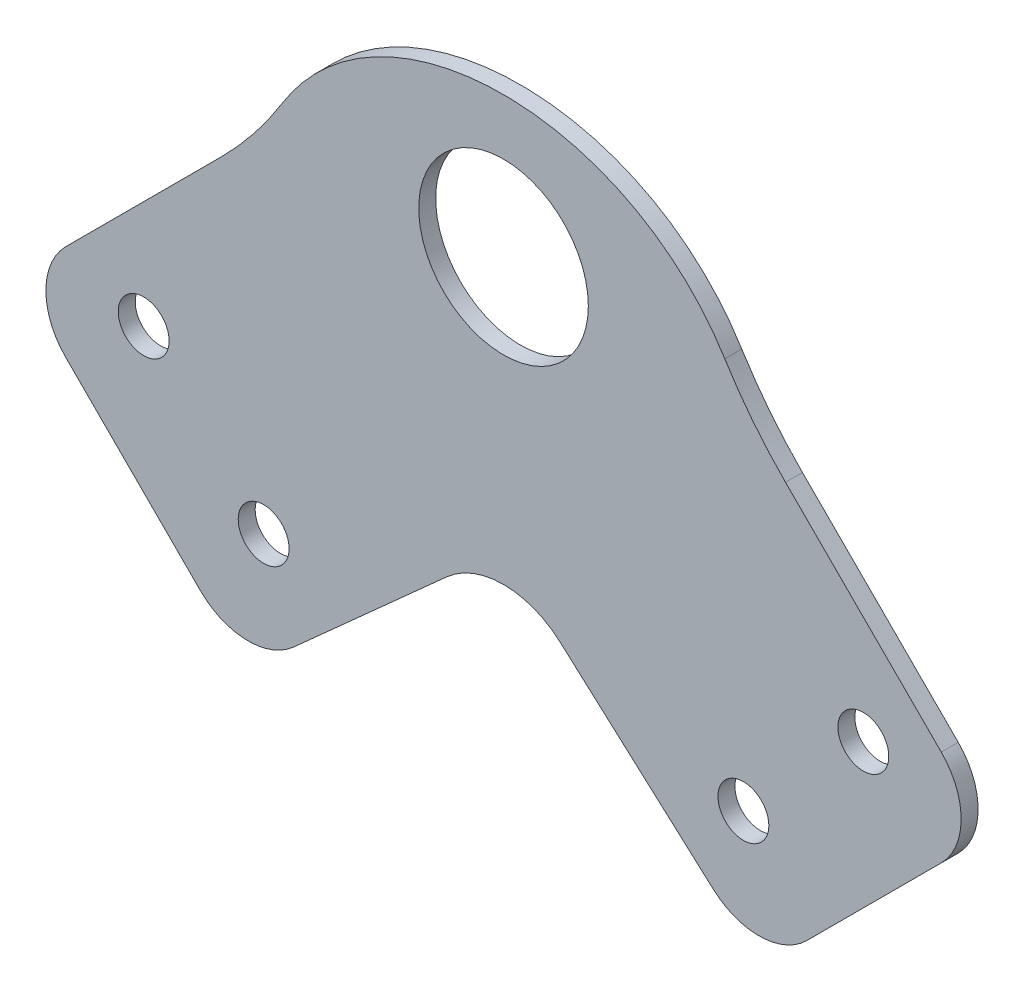
from build123d import *

# Parameters (mm, degrees)
SKETCH1_R           = 10
SKETCH1_R_2         = 3
BOSS_EXTRUDE1_DEPTH = 2
FILLET1_R           = 10
FILLET2_R           = 8
FILLET3_R           = 50


with BuildPart() as part:
    # Sketch1 → Boss-Extrude1 (new body)
    with BuildSketch(Plane.XY):
        with BuildLine():
            Line((-57.275649276, -30.405591591), (-28.125846456, -1.255788771))
            add(Edge.make_bspline(
                [(-28.125846456, -1.255788771), (-17.904305408, 22.543934761), (17.904305408, 22.543934761), (28.125846456, -1.255788771)],
                knots=[0, 0, 0, 0, 1, 1, 1, 1], degree=3))
            Line((28.125846456, -1.255788771), (57.275649276, -30.405591591))
            Line((57.275649276, -30.405591591), (30.405591591, -57.275649276))
            Line((30.405591591, -57.275649276), (0, -30))
            Line((0, -30), (-30.405591591, -57.275649276))
            Line((-30.405591591, -57.275649276), (-57.275649276, -30.405591591))
        make_face()
        Circle(SKETCH1_R, mode=Mode.SUBTRACT)
        with Locations((-42.426406871, -28.284271247)):
            Circle(SKETCH1_R_2, mode=Mode.SUBTRACT)
        with Locations((-28.284271247, -42.426406871)):
            Circle(SKETCH1_R_2, mode=Mode.SUBTRACT)
        with Locations((28.284271247, -42.426406871)):
            Circle(SKETCH1_R_2, mode=Mode.SUBTRACT)
        with Locations((42.426406871, -28.284271247)):
            Circle(SKETCH1_R_2, mode=Mode.SUBTRACT)
    extrude(amount=BOSS_EXTRUDE1_DEPTH)

    # Fillet1
    fillet1_edges = [part.edges().sort_by_distance(p)[0] for p in [
        (0, -30, 1),
    ]]
    fillet(fillet1_edges, radius=FILLET1_R)

    # Fillet2
    fillet2_edges = [part.edges().sort_by_distance(p)[0] for p in [
        (-57.275649276, -30.405591591, 1),
        (57.275649276, -30.405591591, 1),
        (30.405591591, -57.275649276, 1),
        (-30.405591591, -57.275649276, 1),
    ]]
    fillet(fillet2_edges, radius=FILLET2_R)

    # Fillet3
    fillet3_edges = [part.edges().sort_by_distance(p)[0] for p in [
        (-28.125846456, -1.255788771, 1),
        (28.125846456, -1.255788771, 1),
    ]]
    fillet(fillet3_edges, radius=FILLET3_R)


solid = part.part
